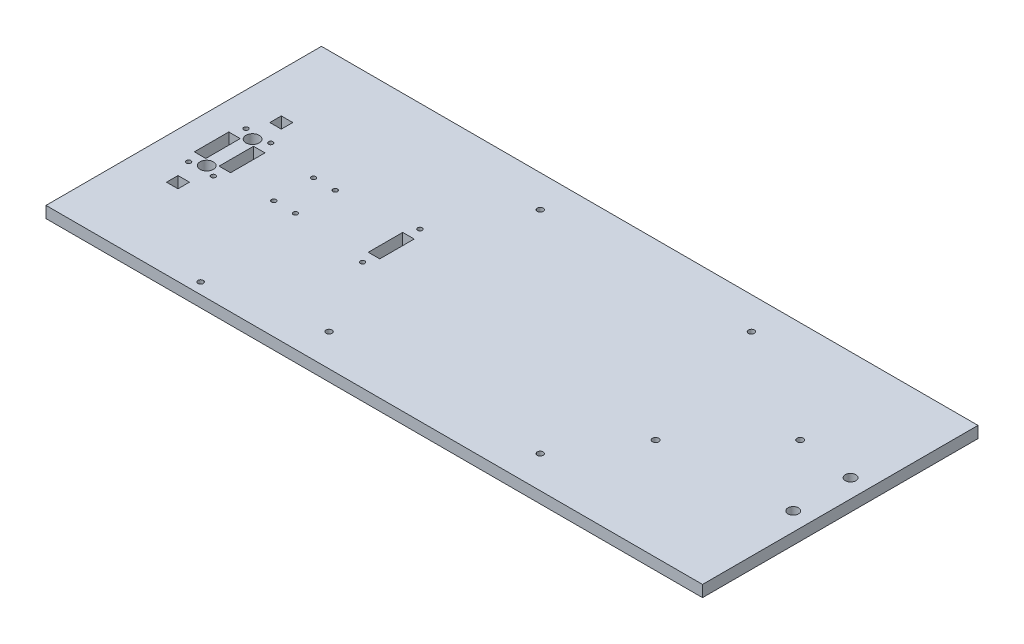
from build123d import *

# Parameters (mm, degrees)
SKETCH1_W           = 363.22
SKETCH1_H           = 152.4
SKETCH1_R           = 3.6703
SKETCH1_R_2         = 2.921
BOSS_EXTRUDE1_DEPTH = 6.35
SKETCH2_W           = 6.35
SKETCH2_H           = 6.35
SKETCH2_H_2         = 19.05000003
SKETCH2_H_3         = 19.05
CUT_EXTRUDE1_DEPTH  = 7.35
SKETCH5_R           = 1.5
CUT_EXTRUDE2_DEPTH  = 7.35
SKETCH7_R           = 1.651
CUT_EXTRUDE3_DEPTH  = 7.35
SKETCH8_R           = 1.75
CUT_EXTRUDE4_DEPTH  = 7.35
SKETCH9_R           = 1.25
CUT_EXTRUDE5_DEPTH  = 7.35
SKETCH10_R          = 1.25
CUT_EXTRUDE6_DEPTH  = 7.35


with BuildPart() as part:
    # Sketch1 → Boss-Extrude1 (new body)
    with BuildSketch(Plane(origin=(0, 0, 0), x_dir=(1, 0, 0), z_dir=(0, 1, 0))):
        with Locations((181.61, 76.2)):
            Rectangle(SKETCH1_W, SKETCH1_H)
        with Locations((25.4, 63.5)):
            Circle(SKETCH1_R, mode=Mode.SUBTRACT)
        with Locations((25.4, 88.9)):
            Circle(SKETCH1_R, mode=Mode.SUBTRACT)
        with Locations((353.06, 60.325)):
            Circle(SKETCH1_R_2, mode=Mode.SUBTRACT)
        with Locations((353.06, 92.075)):
            Circle(SKETCH1_R_2, mode=Mode.SUBTRACT)
    extrude(amount=BOSS_EXTRUDE1_DEPTH)

    # Sketch2 → Cut-Extrude1 (cut, through all)
    with BuildSketch(Plane(origin=(0, 6.35, 0), x_dir=(1, 0, 0), z_dir=(0, 1, 0))):
        with Locations((25.4, 104.775)):
            Rectangle(SKETCH2_W, SKETCH2_H)
        with Locations((25.4, 47.625)):
            Rectangle(SKETCH2_W, SKETCH2_H)
        with Locations((32.2453, 76.2)):
            Rectangle(SKETCH2_W, SKETCH2_H_2)
        with Locations((18.5547, 76.199999985)):
            Rectangle(SKETCH2_W, SKETCH2_H_3)
        with Locations((114.7953, 76.2)):
            Rectangle(SKETCH2_W, SKETCH2_H_2)
    extrude(amount=-CUT_EXTRUDE1_DEPTH, mode=Mode.SUBTRACT)

    # Sketch5 → Cut-Extrude2 (cut, through all)
    with BuildSketch(Plane(origin=(0, 6.35, 0), x_dir=(1, 0, 0), z_dir=(0, 1, 0))):
        with Locations((79.4639, 6.096)):
            Circle(SKETCH5_R)
    extrude(amount=-CUT_EXTRUDE2_DEPTH, mode=Mode.SUBTRACT)

    # Sketch7 → Cut-Extrude3 (cut, through all)
    with BuildSketch(Plane(origin=(0, 6.35, 0), x_dir=(1, 0, 0), z_dir=(0, 1, 0))):
        with Locations((138.807883042, 134.62)):
            Circle(SKETCH7_R)
        with Locations((255.647883042, 134.62)):
            Circle(SKETCH7_R)
        with Locations((255.647883042, 17.78)):
            Circle(SKETCH7_R)
        with Locations((138.807883042, 17.78)):
            Circle(SKETCH7_R)
    extrude(amount=-CUT_EXTRUDE3_DEPTH, mode=Mode.SUBTRACT)

    # Sketch8 → Cut-Extrude4 (cut, through all)
    with BuildSketch(Plane(origin=(0, 6.35, 0), x_dir=(1, 0, 0), z_dir=(0, 1, 0))):
        with Locations((321.047883042, 96.2)):
            Circle(SKETCH8_R)
        with Locations((281.047883042, 56.2)):
            Circle(SKETCH8_R)
    extrude(amount=-CUT_EXTRUDE4_DEPTH, mode=Mode.SUBTRACT)

    # Sketch9 → Cut-Extrude5 (cut, through all)
    with BuildSketch(Plane(origin=(0, 6.35, 0), x_dir=(1, 0, 0), z_dir=(0, 1, 0))):
        with Locations((18.5547, 92.074999985)):
            Circle(SKETCH9_R)
        with Locations((32.2453, 92.075000015)):
            Circle(SKETCH9_R)
        with Locations((32.2453, 60.324999985)):
            Circle(SKETCH9_R)
        with Locations((18.5547, 60.324999985)):
            Circle(SKETCH9_R)
        with Locations((114.7953, 92.075000015)):
            Circle(SKETCH9_R)
        with Locations((114.7953, 60.324999985)):
            Circle(SKETCH9_R)
    extrude(amount=-CUT_EXTRUDE5_DEPTH, mode=Mode.SUBTRACT)

    # Sketch10 → Cut-Extrude6 (cut, through all)
    with BuildSketch(Plane(origin=(0, 6.35, 0), x_dir=(1, 0, 0), z_dir=(0, 1, 0))):
        with Locations((60.8203, 87.2)):
            Circle(SKETCH10_R)
        with Locations((72.8203, 87.2)):
            Circle(SKETCH10_R)
        with Locations((72.8203, 65.2)):
            Circle(SKETCH10_R)
        with Locations((60.8203, 65.2)):
            Circle(SKETCH10_R)
    extrude(amount=-CUT_EXTRUDE6_DEPTH, mode=Mode.SUBTRACT)


solid = part.part
